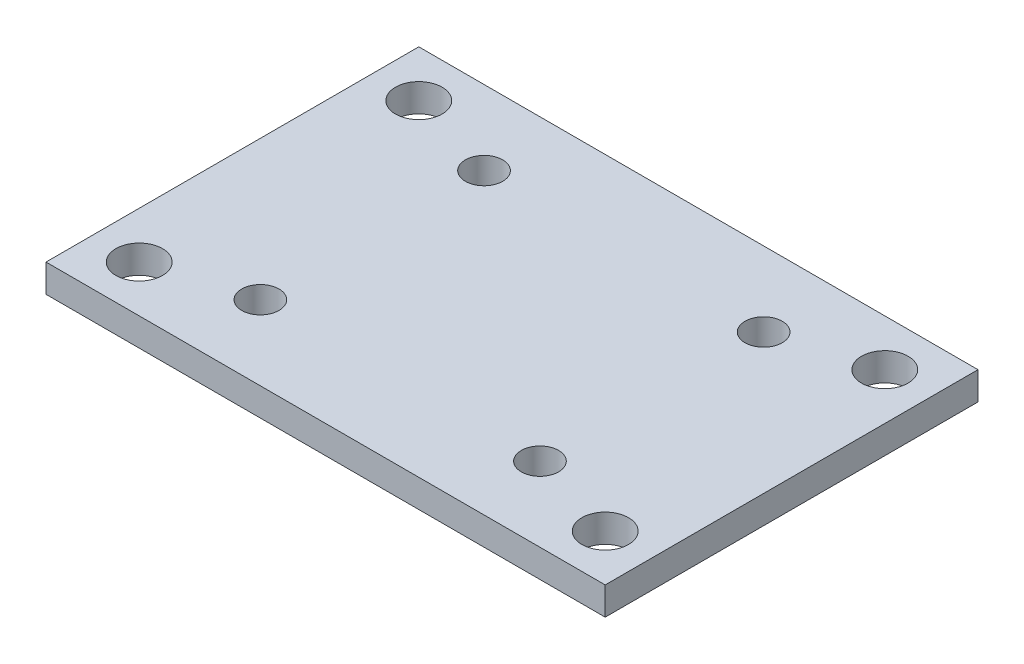
from build123d import *

# Parameters (mm, degrees)
SKETCH1_W           = 60
SKETCH1_H           = 40
BOSS_EXTRUDE1_DEPTH = 3
SKETCH2_R           = 2
CUT_EXTRUDE1_DEPTH  = 3
SKETCH3_R           = 2.5
CUT_EXTRUDE2_DEPTH  = 3


with BuildPart() as part:
    # Sketch1 → Boss-Extrude1 (new body)
    with BuildSketch(Plane(origin=(0, 0, 0), x_dir=(1, 0, 0), z_dir=(0, 1, 0))):
        Rectangle(SKETCH1_W, SKETCH1_H)
    extrude(amount=BOSS_EXTRUDE1_DEPTH)

    # Sketch2 → Cut-Extrude1 (cut)
    with BuildSketch(Plane(origin=(0, 3, 0), x_dir=(1, 0, 0), z_dir=(0, 1, 0))):
        with Locations((-15, 12)):
            Circle(SKETCH2_R)
        with Locations((15, 12)):
            Circle(SKETCH2_R)
        with Locations((15, -12)):
            Circle(SKETCH2_R)
        with Locations((-15, -12)):
            Circle(SKETCH2_R)
    extrude(amount=-CUT_EXTRUDE1_DEPTH, mode=Mode.SUBTRACT)

    # Sketch3 → Cut-Extrude2 (cut)
    with BuildSketch(Plane(origin=(0, 3, 0), x_dir=(1, 0, 0), z_dir=(0, 1, 0))):
        with Locations((-25, 15)):
            Circle(SKETCH3_R)
        with Locations((-25, -15)):
            Circle(SKETCH3_R)
        with Locations((25, 15)):
            Circle(SKETCH3_R)
        with Locations((25, -15)):
            Circle(SKETCH3_R)
    extrude(amount=-CUT_EXTRUDE2_DEPTH, mode=Mode.SUBTRACT)


solid = part.part
